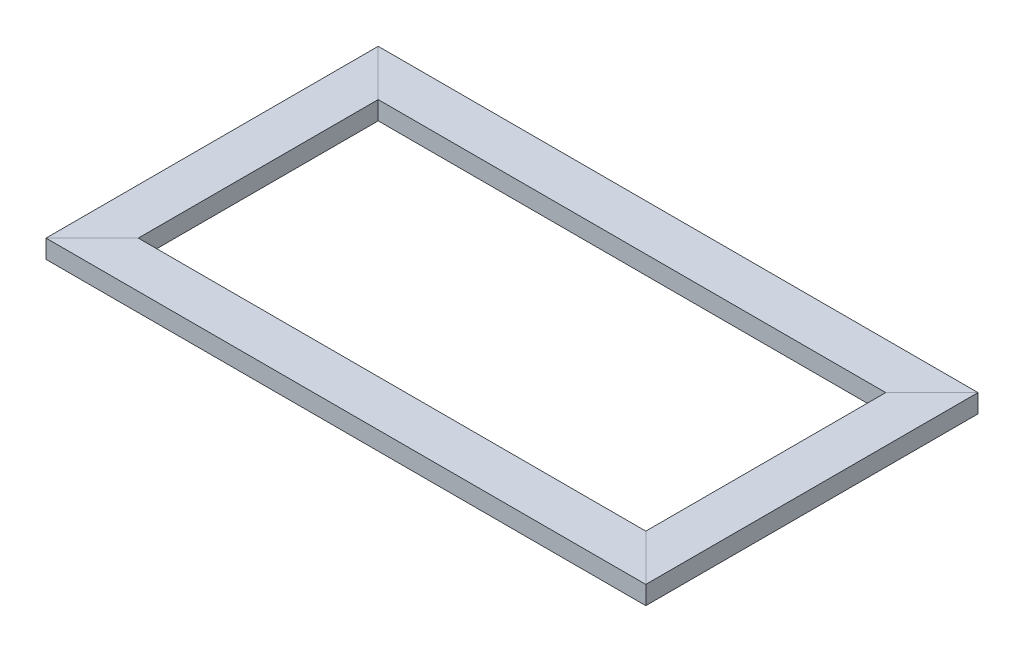
from build123d import *

# Parameters (mm, degrees)
SKETCH1_W = 50
SKETCH1_H = 20


with BuildPart() as part:
    # Sweep1: sweep along a curve in space
    with BuildLine() as sweep1_path:
        Line((0, 0, 0), (650, 0, 0))
        Line((650, 0, 0), (650, 0, -360))
        Line((650, 0, -360), (0, 0, -360))
        Line((0, 0, -360), (0, 0, 0))
    # Sketch1 → Sweep1 (sweep)
    with BuildSketch(Plane(origin=(0, 0, 0), x_dir=(0, 0, -1), z_dir=(1, 0, 0))):
        with Locations((25, 10)):
            Rectangle(SKETCH1_W, SKETCH1_H)
    sweep(path=sweep1_path.line, transition=Transition.RIGHT)


solid = part.part
